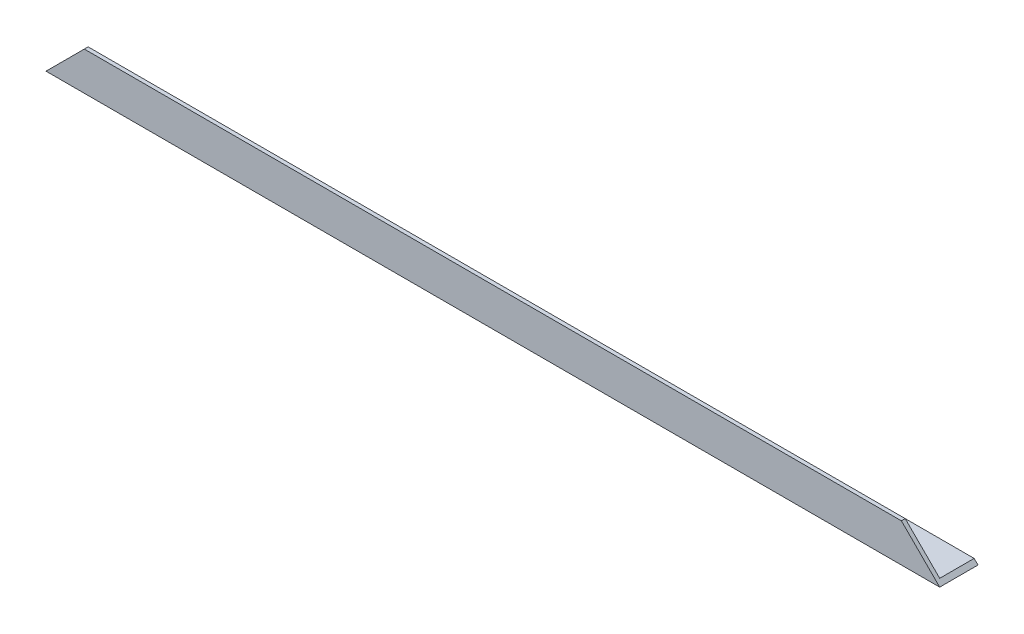
from build123d import *

# Parameters (mm, degrees)
EXTRUDE_1_DEPTH     = 350
CUT_EXTRUDE_1_DEPTH = 16


with BuildPart() as part:
    # Эскиз1 → Бобышка-Вытянуть1 (new body)
    with BuildSketch(Plane(origin=(0, 0, 0), x_dir=(0, 0, -1), z_dir=(1, 0, 0))):
        Polygon((0, 0), (0, 15), (1.5, 15), (1.5, 1.5), (15, 1.5), (15, 0), align=None)
    extrude(amount=EXTRUDE_1_DEPTH)

    # Эскиз2 → Вырез-Вытянуть1 (cut, through all)
    with BuildSketch(Plane.XY):
        Polygon((0, 0), (21.729873861, 21.729873861), (0, 21.729873861), align=None)
    cut_extrude_1 = extrude(amount=-CUT_EXTRUDE_1_DEPTH, mode=Mode.SUBTRACT)

    # Зеркальное отражение1: Вырез-Вытянуть1 across plane
    add(cut_extrude_1.mirror(Plane.ZY.offset(-175)), mode=Mode.SUBTRACT)


solid = part.part
